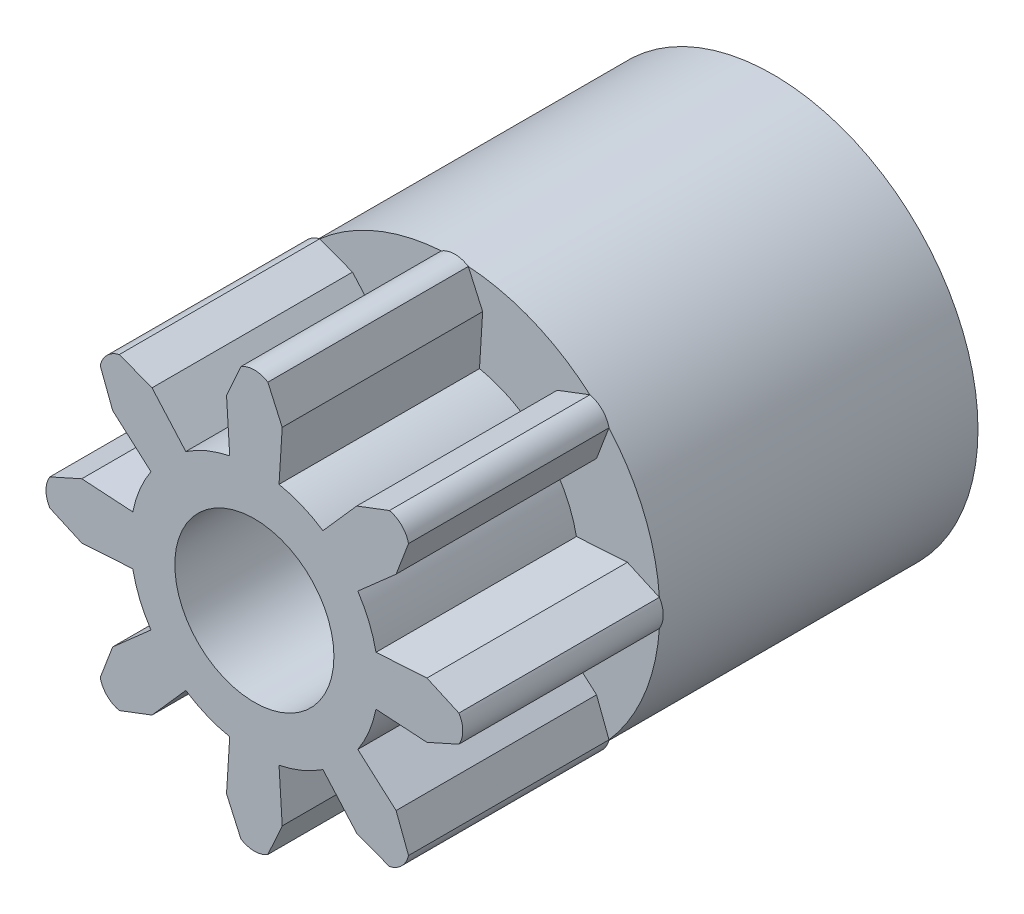
from build123d import *

# Parameters (mm, degrees)
SZKIC1_R                    = 2.5
DODANIE_WYCI_GNI_CIE1_DEPTH = 6.3
SKETCH1_R                   = 6.441701171
SKETCH1_R_2                 = 2.5
BOSS_EXTRUDE1_DEPTH         = 10


with BuildPart() as part:
    # Szkic1 → Dodanie-wyciągnięcie1 (new body)
    with BuildSketch(Plane.XY):
        with BuildLine():
            Line((0.875, 5.423398291), (0.775, 3.822221213))
            ThreePointArc((0.775, 3.822221213), (1.492465386, 3.603130177), (2.154710783, 3.250726294))
            Line((2.154710783, 3.250726294), (3.216203275, 4.453640142))
            Line((3.216203275, 4.453640142), (4.245186445, 4.844987722))
            ThreePointArc((4.245186445, 4.844987722), (4.453444634, 4.765560203), (4.631549417, 4.631549417))
            ThreePointArc((4.631549417, 4.631549417), (4.765560203, 4.453444634), (4.844987722, 4.245186445))
            Line((4.844987722, 4.245186445), (4.453640142, 3.216203275))
            Line((4.453640142, 3.216203275), (3.250726294, 2.154710783))
            ThreePointArc((3.250726294, 2.154710783), (3.603130177, 1.492465386), (3.822221213, 0.775))
            Line((3.822221213, 0.775), (5.423398291, 0.875))
            Line((5.423398291, 0.875), (6.427723795, 0.424123551))
            ThreePointArc((6.427723795, 0.424123551), (6.518820836, 0.220699035), (6.55, 0))
            ThreePointArc((6.55, 0), (6.518820836, -0.220699035), (6.427723795, -0.424123551))
            Line((6.427723795, -0.424123551), (5.423398291, -0.875))
            Line((5.423398291, -0.875), (3.822221213, -0.775))
            ThreePointArc((3.822221213, -0.775), (3.603130177, -1.492465386), (3.250726294, -2.154710783))
            Line((3.250726294, -2.154710783), (4.453640142, -3.216203275))
            Line((4.453640142, -3.216203275), (4.844987722, -4.245186445))
            ThreePointArc((4.844987722, -4.245186445), (4.765560203, -4.453444634), (4.631549417, -4.631549417))
            ThreePointArc((4.631549417, -4.631549417), (4.453444634, -4.765560203), (4.245186445, -4.844987722))
            Line((4.245186445, -4.844987722), (3.216203275, -4.453640142))
            Line((3.216203275, -4.453640142), (2.154710783, -3.250726294))
            ThreePointArc((2.154710783, -3.250726294), (1.492465386, -3.603130177), (0.775, -3.822221213))
            Line((0.775, -3.822221213), (0.875, -5.423398291))
            Line((0.875, -5.423398291), (0.424123551, -6.427723795))
            ThreePointArc((0.424123551, -6.427723795), (0.220699035, -6.518820836), (0, -6.55))
            ThreePointArc((0, -6.55), (-0.220699035, -6.518820836), (-0.424123551, -6.427723795))
            Line((-0.424123551, -6.427723795), (-0.875, -5.423398291))
            Line((-0.875, -5.423398291), (-0.775, -3.822221213))
            ThreePointArc((-0.775, -3.822221213), (-1.492465386, -3.603130177), (-2.154710783, -3.250726294))
            Line((-2.154710783, -3.250726294), (-3.216203275, -4.453640142))
            Line((-3.216203275, -4.453640142), (-4.245186445, -4.844987722))
            ThreePointArc((-4.245186445, -4.844987722), (-4.453444634, -4.765560203), (-4.631549417, -4.631549417))
            ThreePointArc((-4.631549417, -4.631549417), (-4.765560203, -4.453444634), (-4.844987722, -4.245186445))
            Line((-4.844987722, -4.245186445), (-4.453640142, -3.216203275))
            Line((-4.453640142, -3.216203275), (-3.250726294, -2.154710783))
            ThreePointArc((-3.250726294, -2.154710783), (-3.603130177, -1.492465386), (-3.822221213, -0.775))
            Line((-3.822221213, -0.775), (-5.423398291, -0.875))
            Line((-5.423398291, -0.875), (-6.427723795, -0.424123551))
            ThreePointArc((-6.427723795, -0.424123551), (-6.518820836, -0.220699035), (-6.55, 0))
            ThreePointArc((-6.55, 0), (-6.518820836, 0.220699035), (-6.427723795, 0.424123551))
            Line((-6.427723795, 0.424123551), (-5.423398291, 0.875))
            Line((-5.423398291, 0.875), (-3.822221213, 0.775))
            ThreePointArc((-3.822221213, 0.775), (-3.603130177, 1.492465386), (-3.250726294, 2.154710783))
            Line((-3.250726294, 2.154710783), (-4.453640142, 3.216203275))
            Line((-4.453640142, 3.216203275), (-4.844987722, 4.245186445))
            ThreePointArc((-4.844987722, 4.245186445), (-4.765560203, 4.453444634), (-4.631549417, 4.631549417))
            ThreePointArc((-4.631549417, 4.631549417), (-4.453444634, 4.765560203), (-4.245186445, 4.844987722))
            Line((-4.245186445, 4.844987722), (-3.216203275, 4.453640142))
            Line((-3.216203275, 4.453640142), (-2.154710783, 3.250726294))
            ThreePointArc((-2.154710783, 3.250726294), (-1.492465386, 3.603130177), (-0.775, 3.822221213))
            Line((-0.775, 3.822221213), (-0.875, 5.423398291))
            Line((-0.875, 5.423398291), (-0.424123551, 6.427723795))
            ThreePointArc((-0.424123551, 6.427723795), (-0.220699035, 6.518820836), (0, 6.55))
            ThreePointArc((0, 6.55), (0.220699035, 6.518820836), (0.424123551, 6.427723795))
            Line((0.424123551, 6.427723795), (0.875, 5.423398291))
        make_face()
        Circle(SZKIC1_R, mode=Mode.SUBTRACT)
    extrude(amount=DODANIE_WYCI_GNI_CIE1_DEPTH)

    # Sketch1 → Boss-Extrude1 (add)
    with BuildSketch(Plane.XY):
        Circle(SKETCH1_R)
        Circle(SKETCH1_R_2, mode=Mode.SUBTRACT)
    extrude(amount=-BOSS_EXTRUDE1_DEPTH)


solid = part.part
